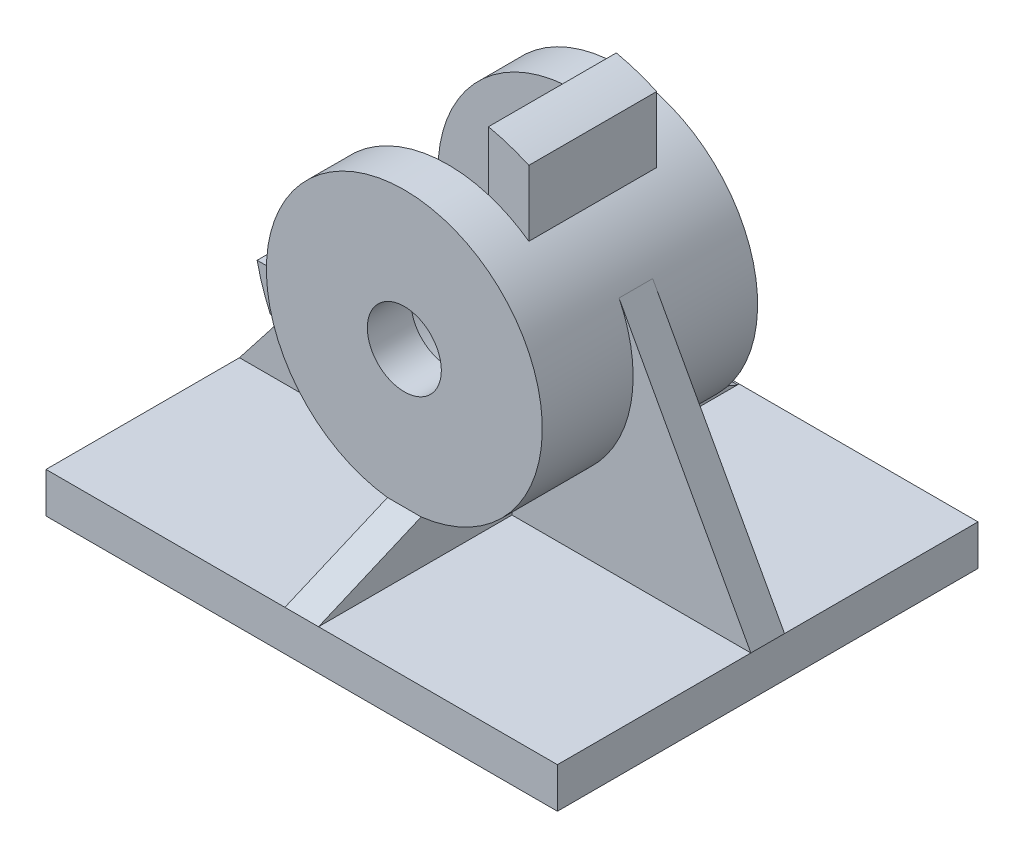
from build123d import *

# Parameters (mm, degrees)
SKETCH1_W           = 152
SKETCH1_H           = 12
BOSS_EXTRUDE1_DEPTH = 125
SKETCH3_W           = 10
SKETCH3_H           = 85
BOSS_EXTRUDE2_DEPTH = 152
SKETCH4_W           = 10
SKETCH4_H           = 39
BOSS_EXTRUDE3_DEPTH = 125
BOSS_EXTRUDE4_DEPTH = 38
BOSS_EXTRUDE5_DEPTH = 38
CUT_EXTRUDE1_DEPTH  = 38
CUT_EXTRUDE2_DEPTH  = 38
SKETCH10_R          = 41
SKETCH10_R_2        = 14
BOSS_EXTRUDE6_DEPTH = 13
CUT_EXTRUDE4_DEPTH  = 13
SKETCH13_R          = 29
CUT_EXTRUDE5_DEPTH  = 38
SKETCH14_R          = 41
SKETCH14_R_2        = 11
BOSS_EXTRUDE8_DEPTH = 13
CUT_EXTRUDE6_DEPTH  = 13


with BuildPart() as part:
    # Sketch1 → Boss-Extrude1 (new body)
    with BuildSketch(Plane.XY):
        with Locations((76, 6)):
            Rectangle(SKETCH1_W, SKETCH1_H)
    extrude(amount=BOSS_EXTRUDE1_DEPTH)

    # Sketch3 → Boss-Extrude2 (add)
    with BuildSketch(Plane(origin=(0, 0, 0), x_dir=(0, 0, -1), z_dir=(1, 0, 0))):
        with Locations((-62.5, 54.5)):
            Rectangle(SKETCH3_W, SKETCH3_H)
    extrude(amount=BOSS_EXTRUDE2_DEPTH)

    # Sketch4 → Boss-Extrude3 (add)
    with BuildSketch(Plane.XY):
        with Locations((76, 31.5)):
            Rectangle(SKETCH4_W, SKETCH4_H)
    extrude(amount=BOSS_EXTRUDE3_DEPTH)

    # Sketch5 → Boss-Extrude4 (add)
    with BuildSketch(Plane(origin=(0, 0, 43.5), x_dir=(-1, 0, 0), z_dir=(0, 0, -1))):
        with BuildLine():
            Line((-36.795408432, 53.709899764), (-49.599242435, 53.709899764))
            ThreePointArc((-49.599242435, 53.709899764), (-96.506096654, 45.20380311), (-88, 92.110657329))
            Line((-88, 92.110657329), (-88, 104.914491332))
            ThreePointArc((-88, 104.914491332), (-104.991378029, 36.718521736), (-36.795408432, 53.709899764))
        make_face()
    extrude(amount=-BOSS_EXTRUDE4_DEPTH)

    # Sketch7 → Boss-Extrude5 (add)
    with BuildSketch(Plane(origin=(0, 0, 43.5), x_dir=(-1, 0, 0), z_dir=(0, 0, -1))):
        with BuildLine():
            ThreePointArc((-88, 104.914491332), (-94.245259526, 102.42652413), (-100, 98.951440042))
            Line((-100, 98.951440042), (-100, 118.511414894))
            ThreePointArc((-100, 118.511414894), (-94.107673916, 120.810826665), (-88, 122.454943601))
            Line((-88, 122.454943601), (-88, 104.914491332))
        make_face()
        with BuildLine():
            Line((-23.19848487, 41.709899764), (-42.758459723, 41.709899764))
            ThreePointArc((-42.758459723, 41.709899764), (-39.283375634, 47.464640238), (-36.795408432, 53.709899764))
            Line((-36.795408432, 53.709899764), (-19.254956164, 53.709899764))
            ThreePointArc((-19.254956164, 53.709899764), (-20.899073099, 47.602225848), (-23.19848487, 41.709899764))
        make_face()
    extrude(amount=-BOSS_EXTRUDE5_DEPTH)

    # Sketch8 → Cut-Extrude1 (cut)
    with BuildSketch(Plane(origin=(0, 0, 57.5), x_dir=(-1, 0, 0), z_dir=(0, 0, -1))):
        with BuildLine():
            Line((-152, 12), (-112.808217889, 83.76966432))
            ThreePointArc((-112.808217889, 83.76966432), (-108.334991946, 90.917999571), (-102.493954541, 97))
            Line((-102.493954541, 97), (-152, 97))
            Line((-152, 97), (-152, 12))
        make_face()
    extrude(amount=-CUT_EXTRUDE1_DEPTH, mode=Mode.SUBTRACT)

    # Sketch9 → Cut-Extrude2 (cut)
    with BuildSketch(Plane(origin=(0, 0, 43.5), x_dir=(-1, 0, 0), z_dir=(0, 0, -1))):
        with BuildLine():
            Line((0, 12), (-23.19848487, 41.709899764))
            ThreePointArc((-23.19848487, 41.709899764), (-20.899073099, 47.602225848), (-19.254956164, 53.709899764))
            Line((-19.254956164, 53.709899764), (-49.599242435, 53.709899764))
            ThreePointArc((-49.599242435, 53.709899764), (-58.248729295, 42.777556047), (-71, 37.14418605))
            Line((-71, 37.14418605), (-71, 51))
            Line((-71, 51), (-81, 51))
            Line((-81, 51), (-81, 37.14418605))
            ThreePointArc((-81, 37.14418605), (-104.767659641, 62.046327903), (-88, 92.110657329))
            Line((-88, 92.110657329), (-88, 97))
            Line((-88, 97), (0, 97))
            Line((0, 97), (0, 12))
        make_face()
    extrude(amount=-CUT_EXTRUDE2_DEPTH, mode=Mode.SUBTRACT)

    # Sketch10 → Boss-Extrude6 (add)
    with BuildSketch(Plane(origin=(0, 0, 43.5), x_dir=(-1, 0, 0), z_dir=(0, 0, -1))):
        with Locations((-76, 65.709899764)):
            Circle(SKETCH10_R)
        with Locations((-76, 65.709899764)):
            Circle(SKETCH10_R_2, mode=Mode.SUBTRACT)
    extrude(amount=BOSS_EXTRUDE6_DEPTH)

    # Sketch11 → Cut-Extrude4 (cut)
    with BuildSketch(Plane(origin=(81, 0, 0), x_dir=(0, 0, -1), z_dir=(1, 0, 0))):
        Polygon((-30.5, 25.015919866), (-30.5, 51), (0, 51), (0, 12), (-0.340530313, 11.874434651), align=None)
    extrude(amount=-CUT_EXTRUDE4_DEPTH, mode=Mode.SUBTRACT)

    # Sketch13 → Cut-Extrude5 (cut)
    with BuildSketch(Plane(origin=(0, 0, 43.5), x_dir=(-1, 0, 0), z_dir=(0, 0, -1))):
        with Locations((-76, 65.709899764)):
            Circle(SKETCH13_R)
    extrude(amount=-CUT_EXTRUDE5_DEPTH, mode=Mode.SUBTRACT)

    # Sketch14 → Boss-Extrude8 (add)
    with BuildSketch(Plane.XY.offset(81.5)):
        with Locations((76, 65.709899764)):
            Circle(SKETCH14_R)
        with Locations((76, 65.709899764)):
            Circle(SKETCH14_R_2, mode=Mode.SUBTRACT)
    extrude(amount=BOSS_EXTRUDE8_DEPTH)

    # Sketch15 → Cut-Extrude6 (cut)
    with BuildSketch(Plane.ZY.offset(-71)):
        Polygon((125, 12), (94.5, 25.015919866), (94.5, 51), (125, 51), align=None)
    extrude(amount=-CUT_EXTRUDE6_DEPTH, mode=Mode.SUBTRACT)


solid = part.part
